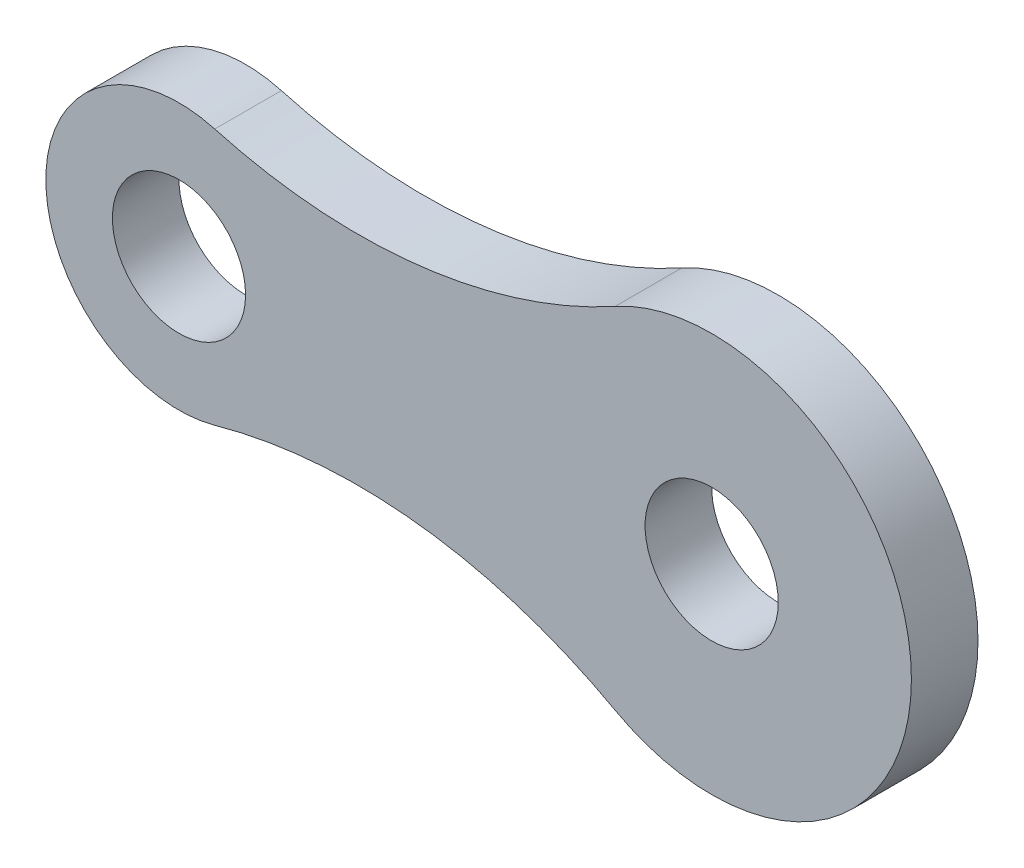
from build123d import *

# Parameters (mm, degrees)
SKETCH1_R           = 12.7
BOSS_EXTRUDE1_DEPTH = 12.7


with BuildPart() as part:
    # Sketch1 → Boss-Extrude1 (new body)
    with BuildSketch(Plane.XY):
        with BuildLine():
            ThreePointArc((6.82625, 24.465533122), (-25.4, 0), (6.82625, -24.465533122))
            ThreePointArc((6.82625, -24.465533122), (45.886938178, -21.410056663), (83.199431818, -33.362090621))
            ThreePointArc((83.199431818, -33.362090621), (139.7, 0), (83.199431818, 33.362090621))
            ThreePointArc((83.199431818, 33.362090621), (45.886938178, 21.410056663), (6.82625, 24.465533122))
        make_face()
        Circle(SKETCH1_R, mode=Mode.SUBTRACT)
        with Locations((101.6, 0)):
            Circle(SKETCH1_R, mode=Mode.SUBTRACT)
    extrude(amount=BOSS_EXTRUDE1_DEPTH)


solid = part.part
